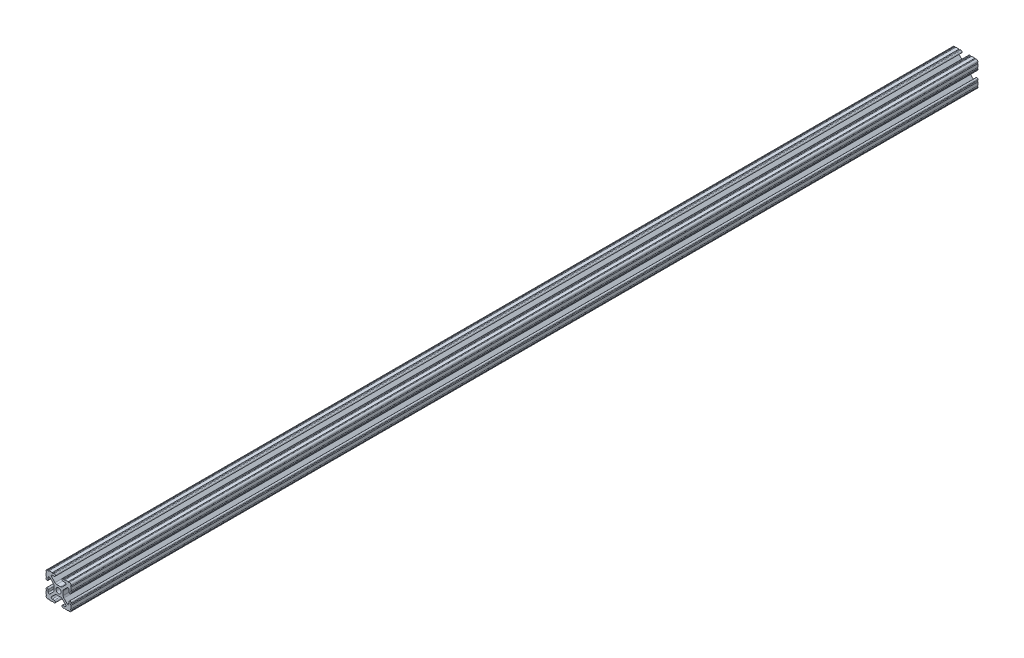
from build123d import *

# Parameters (mm, degrees)
SKETCH3_W                = 25.4
SKETCH3_H                = 25.4
BOSS_EXTRUDE1_DEPTH      = 457.2
BOSS_EXTRUDE1_DEPTH_BACK = 457.2
SKETCH4_R                = 2.6035
CUT_EXTRUDE1_DEPTH       = 915.4
CUT_EXTRUDE2_DEPTH       = 915.4
FILLET1_R                = 2.54
FILLET2_R                = 1.778


with BuildPart() as part:
    # Sketch3 → Boss-Extrude1 (new body, two sides)
    with BuildSketch(Plane.XY) as boss_extrude1_sk:
        Rectangle(SKETCH3_W, SKETCH3_H)
    extrude(amount=BOSS_EXTRUDE1_DEPTH)
    extrude(boss_extrude1_sk.sketch, amount=-BOSS_EXTRUDE1_DEPTH_BACK)

    # Sketch4 → Cut-Extrude1 (cut, through all)
    with BuildSketch(Plane.XY.offset(457.2)):
        with BuildLine():
            Line((3.2512, 12.7), (-3.2512, 12.7))
            Line((-3.2512, 12.7), (-3.2512, 10.4902))
            Line((-3.2512, 10.4902), (-6.348478019, 10.4902))
            ThreePointArc((-6.348478019, 10.4902), (-7.335478831, 9.830707141), (-7.103895736, 8.666460301))
            Line((-7.103895736, 8.666460301), (-2.958635435, 4.5212))
            Line((-2.958635435, 4.5212), (2.958635435, 4.5212))
            Line((2.958635435, 4.5212), (7.103895736, 8.666460301))
            ThreePointArc((7.103895736, 8.666460301), (7.335478831, 9.830707141), (6.348478019, 10.4902))
            Line((6.348478019, 10.4902), (3.2512, 10.4902))
            Line((3.2512, 10.4902), (3.2512, 12.7))
        make_face()
        with BuildLine():
            Line((12.7, -3.2512), (12.7, 3.2512))
            Line((12.7, 3.2512), (10.4902, 3.2512))
            Line((10.4902, 3.2512), (10.4902, 6.348478019))
            ThreePointArc((10.4902, 6.348478019), (9.830707141, 7.335478831), (8.666460301, 7.103895736))
            Line((8.666460301, 7.103895736), (4.5212, 2.958635435))
            Line((4.5212, 2.958635435), (4.5212, -2.958635435))
            Line((4.5212, -2.958635435), (8.666460301, -7.103895736))
            ThreePointArc((8.666460301, -7.103895736), (9.830707141, -7.335478831), (10.4902, -6.348478019))
            Line((10.4902, -6.348478019), (10.4902, -3.2512))
            Line((10.4902, -3.2512), (12.7, -3.2512))
        make_face()
        with BuildLine():
            Line((-3.2512, -10.4902), (-3.2512, -12.7))
            Line((-3.2512, -12.7), (3.2512, -12.7))
            Line((3.2512, -12.7), (3.2512, -10.4902))
            Line((3.2512, -10.4902), (6.348478019, -10.4902))
            ThreePointArc((6.348478019, -10.4902), (7.335478831, -9.830707141), (7.103895736, -8.666460301))
            Line((7.103895736, -8.666460301), (2.958635435, -4.5212))
            Line((2.958635435, -4.5212), (-2.958635435, -4.5212))
            Line((-2.958635435, -4.5212), (-7.103895736, -8.666460301))
            ThreePointArc((-7.103895736, -8.666460301), (-7.335478831, -9.830707141), (-6.348478019, -10.4902))
            Line((-6.348478019, -10.4902), (-3.2512, -10.4902))
        make_face()
        with BuildLine():
            Line((-10.4902, 3.2512), (-12.7, 3.2512))
            Line((-12.7, 3.2512), (-12.7, -3.2512))
            Line((-12.7, -3.2512), (-10.4902, -3.2512))
            Line((-10.4902, -3.2512), (-10.4902, -6.348478019))
            ThreePointArc((-10.4902, -6.348478019), (-9.830707141, -7.335478831), (-8.666460301, -7.103895736))
            Line((-8.666460301, -7.103895736), (-4.5212, -2.958635435))
            Line((-4.5212, -2.958635435), (-4.5212, 2.958635435))
            Line((-4.5212, 2.958635435), (-8.666460301, 7.103895736))
            ThreePointArc((-8.666460301, 7.103895736), (-9.830707141, 7.335478831), (-10.4902, 6.348478019))
            Line((-10.4902, 6.348478019), (-10.4902, 3.2512))
        make_face()
        Circle(SKETCH4_R)
    extrude(amount=-CUT_EXTRUDE1_DEPTH, mode=Mode.SUBTRACT)

    # Sketch5 → Cut-Extrude2 (cut, through all)
    with BuildSketch(Plane.XY.offset(457.2)):
        with BuildLine():
            ThreePointArc((-11.5951, 3.2512), (-12.376382283, 3.574817717), (-12.7, 4.3561))
            Line((-12.7, 4.3561), (-12.7, 3.2512))
            Line((-12.7, 3.2512), (-11.5951, 3.2512))
        make_face()
        with BuildLine():
            ThreePointArc((-10.4902, 4.3561), (-10.813817717, 3.574817717), (-11.5951, 3.2512))
            Line((-11.5951, 3.2512), (-10.4902, 3.2512))
            Line((-10.4902, 3.2512), (-10.4902, 4.3561))
        make_face()
        with BuildLine():
            Line((-12.7, -3.2512), (-12.7, -4.3561))
            ThreePointArc((-12.7, -4.3561), (-12.376382283, -3.574817717), (-11.5951, -3.2512))
            Line((-11.5951, -3.2512), (-12.7, -3.2512))
        make_face()
        with BuildLine():
            Line((-10.4902, -3.2512), (-11.5951, -3.2512))
            ThreePointArc((-11.5951, -3.2512), (-10.813817717, -3.574817717), (-10.4902, -4.3561))
            Line((-10.4902, -4.3561), (-10.4902, -3.2512))
        make_face()
        with BuildLine():
            Line((-3.2512, -11.595100007), (-3.2512, -10.4902))
            Line((-3.2512, -10.4902), (-4.3561, -10.4902))
            ThreePointArc((-4.3561, -10.4902), (-3.574817715, -10.81381772), (-3.2512, -11.595100007))
        make_face()
        with BuildLine():
            Line((-3.2512, -12.7), (-3.2512, -11.595100007))
            ThreePointArc((-3.2512, -11.595100007), (-3.57481772, -12.376382285), (-4.3561, -12.7))
            Line((-4.3561, -12.7), (-3.2512, -12.7))
        make_face()
        with BuildLine():
            Line((3.2512, -10.4902), (3.2512, -11.5951))
            ThreePointArc((3.2512, -11.5951), (3.574817718, -10.813817717), (4.3561, -10.4902))
            Line((4.3561, -10.4902), (3.2512, -10.4902))
        make_face()
        with BuildLine():
            Line((3.2512, -12.7), (4.3561, -12.7))
            ThreePointArc((4.3561, -12.7), (3.574817717, -12.376382282), (3.2512, -11.5951))
            Line((3.2512, -11.5951), (3.2512, -12.7))
        make_face()
        with BuildLine():
            Line((11.5951, -3.2512), (10.4902, -3.2512))
            Line((10.4902, -3.2512), (10.4902, -4.3561))
            ThreePointArc((10.4902, -4.3561), (10.813817717, -3.574817717), (11.5951, -3.2512))
        make_face()
        with BuildLine():
            Line((12.7, -3.2512), (11.5951, -3.2512))
            ThreePointArc((11.5951, -3.2512), (12.376382283, -3.574817717), (12.7, -4.3561))
            Line((12.7, -4.3561), (12.7, -3.2512))
        make_face()
        with BuildLine():
            Line((10.4902, 3.2512), (11.5951, 3.2512))
            ThreePointArc((11.5951, 3.2512), (10.813817717, 3.574817717), (10.4902, 4.3561))
            Line((10.4902, 4.3561), (10.4902, 3.2512))
        make_face()
        with BuildLine():
            Line((12.7, 3.2512), (12.7, 4.3561))
            ThreePointArc((12.7, 4.3561), (12.376382283, 3.574817717), (11.5951, 3.2512))
            Line((11.5951, 3.2512), (12.7, 3.2512))
        make_face()
        with BuildLine():
            Line((3.2512, 12.7), (3.2512, 11.595099996))
            ThreePointArc((3.2512, 11.595099996), (3.574817716, 12.376382281), (4.3561, 12.7))
            Line((4.3561, 12.7), (3.2512, 12.7))
        make_face()
        with BuildLine():
            Line((3.2512, 11.595099996), (3.2512, 10.4902))
            Line((3.2512, 10.4902), (4.3561, 10.4902))
            ThreePointArc((4.3561, 10.4902), (3.574817719, 10.813817716), (3.2512, 11.595099996))
        make_face()
        with BuildLine():
            Line((-3.2512, 12.7), (-4.3561, 12.7))
            ThreePointArc((-4.3561, 12.7), (-3.574817717, 12.376382283), (-3.2512, 11.5951))
            Line((-3.2512, 11.5951), (-3.2512, 12.7))
        make_face()
        with BuildLine():
            Line((-3.2512, 10.4902), (-3.2512, 11.5951))
            ThreePointArc((-3.2512, 11.5951), (-3.574817717, 10.813817717), (-4.3561, 10.4902))
            Line((-4.3561, 10.4902), (-3.2512, 10.4902))
        make_face()
        with BuildLine():
            ThreePointArc((-12.7, 5.23875), (-12.14755, 5.7912), (-12.7, 6.34365))
            Line((-12.7, 6.34365), (-12.7, 5.23875))
        make_face()
        with BuildLine():
            ThreePointArc((-12.7, 9.60755), (-12.14755, 10.16), (-12.7, 10.71245))
            Line((-12.7, 10.71245), (-12.7, 9.60755))
        make_face()
        with BuildLine():
            ThreePointArc((-10.71245, 12.7), (-10.16, 12.14755), (-9.60755, 12.7))
            Line((-9.60755, 12.7), (-10.71245, 12.7))
        make_face()
        with BuildLine():
            ThreePointArc((-6.34365, 12.7), (-5.7912, 12.14755), (-5.23875, 12.7))
            Line((-5.23875, 12.7), (-6.34365, 12.7))
        make_face()
        with BuildLine():
            Line((6.34365, 12.7), (5.23875, 12.7))
            ThreePointArc((5.23875, 12.7), (5.7912, 12.14755), (6.34365, 12.7))
        make_face()
        with BuildLine():
            Line((10.71245, 12.7), (9.60755, 12.7))
            ThreePointArc((9.60755, 12.7), (10.16, 12.14755), (10.71245, 12.7))
        make_face()
        with BuildLine():
            Line((12.7, 10.71245), (12.7, 9.60755))
            ThreePointArc((12.7, 9.60755), (12.14755, 10.16), (12.7, 10.71245))
        make_face()
        with BuildLine():
            Line((12.7, 6.34365), (12.7, 5.23875))
            ThreePointArc((12.7, 5.23875), (12.14755, 5.7912), (12.7, 6.34365))
        make_face()
        with BuildLine():
            Line((-12.7, -6.34365), (-12.7, -5.23875))
            ThreePointArc((-12.7, -5.23875), (-12.14755, -5.7912), (-12.7, -6.34365))
        make_face()
        with BuildLine():
            Line((-12.7, -10.71245), (-12.7, -9.60755))
            ThreePointArc((-12.7, -9.60755), (-12.14755, -10.16), (-12.7, -10.71245))
        make_face()
        with BuildLine():
            Line((-10.71245, -12.7), (-9.60755, -12.7))
            ThreePointArc((-9.60755, -12.7), (-10.16, -12.14755), (-10.71245, -12.7))
        make_face()
        with BuildLine():
            Line((-6.34365, -12.7), (-5.23875, -12.7))
            ThreePointArc((-5.23875, -12.7), (-5.7912, -12.14755), (-6.34365, -12.7))
        make_face()
        with BuildLine():
            Line((12.7, -10.71245), (12.7, -9.60755))
            ThreePointArc((12.7, -9.60755), (12.14755, -10.16), (12.7, -10.71245))
        make_face()
        with BuildLine():
            Line((12.7, -6.34365), (12.7, -5.23875))
            ThreePointArc((12.7, -5.23875), (12.14755, -5.7912), (12.7, -6.34365))
        make_face()
        with BuildLine():
            Line((10.71245, -12.7), (9.60755, -12.7))
            ThreePointArc((9.60755, -12.7), (10.16, -12.14755), (10.71245, -12.7))
        make_face()
        with BuildLine():
            Line((6.34365, -12.7), (5.23875, -12.7))
            ThreePointArc((5.23875, -12.7), (5.7912, -12.14755), (6.34365, -12.7))
        make_face()
    extrude(amount=-CUT_EXTRUDE2_DEPTH, mode=Mode.SUBTRACT)

    # Fillet1
    fillet1_edges = [part.edges().sort_by_distance(p)[0] for p in [
        (2.958635435, 4.5212, 0),
        (-2.958635435, 4.5212, 0),
        (-2.958635435, -4.5212, 0),
        (2.958635435, -4.5212, 0),
        (4.5212, -2.958635435, 0),
        (4.5212, 2.958635435, 0),
        (-4.5212, 2.958635435, 0),
        (-4.5212, -2.958635435, 0),
    ]]
    fillet(fillet1_edges, radius=FILLET1_R)

    # Fillet2
    fillet2_edges = [part.edges().sort_by_distance(p)[0] for p in [
        (-12.7, 12.7, 0),
        (12.7, 12.7, 0),
        (12.7, -12.7, 0),
        (-12.7, -12.7, 0),
    ]]
    fillet(fillet2_edges, radius=FILLET2_R)


solid = part.part
